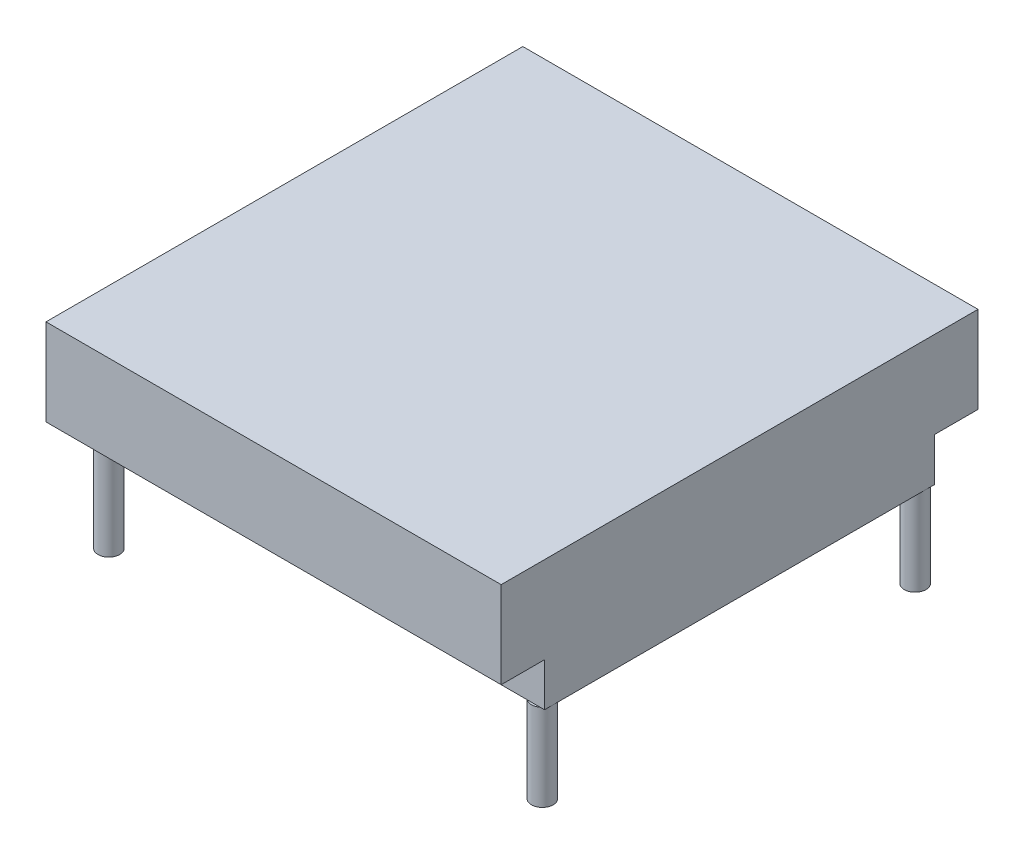
from build123d import *

# Parameters (mm, degrees)
SKETCH1_W           = 133.35
SKETCH1_H           = 139.7
BOSS_EXTRUDE1_DEPTH = 25.4
SKETCH2_W           = 50.8
SKETCH2_H           = 114.3
BOSS_EXTRUDE2_DEPTH = 12.7
SKETCH3_R           = 3.175
BOSS_EXTRUDE3_DEPTH = 38.1
SKETCH4_R           = 3.175
BOSS_EXTRUDE4_DEPTH = 38.1
SKETCH5_R           = 3.175
BOSS_EXTRUDE5_DEPTH = 25.4
SKETCH6_R           = 3.175
BOSS_EXTRUDE6_DEPTH = 25.4


with BuildPart() as part:
    # Sketch1 → Boss-Extrude1 (new body)
    with BuildSketch(Plane(origin=(0, 0, 0), x_dir=(1, 0, 0), z_dir=(0, 1, 0))):
        with Locations((66.675, 42.031328285)):
            Rectangle(SKETCH1_W, SKETCH1_H)
    extrude(amount=BOSS_EXTRUDE1_DEPTH)

    # Sketch2 → Boss-Extrude2 (add)
    with BuildSketch(Plane(origin=(0, 0, 0), x_dir=(-1, 0, 0), z_dir=(0, -1, 0))):
        with Locations((-107.95, 42.031328285)):
            Rectangle(SKETCH2_W, SKETCH2_H)
    extrude(amount=BOSS_EXTRUDE2_DEPTH)

    # Sketch3 → Boss-Extrude3 (add)
    with BuildSketch(Plane(origin=(0, 0, 0), x_dir=(-1, 0, 0), z_dir=(0, -1, 0))):
        with Locations((-3.175, 96.641328285)):
            Circle(SKETCH3_R)
    extrude(amount=BOSS_EXTRUDE3_DEPTH)

    # Sketch4 → Boss-Extrude4 (add)
    with BuildSketch(Plane(origin=(0, 0, 0), x_dir=(-1, 0, 0), z_dir=(0, -1, 0))):
        with Locations((-3.175, -12.578671715)):
            Circle(SKETCH4_R)
    extrude(amount=BOSS_EXTRUDE4_DEPTH)

    # Sketch5 → Boss-Extrude5 (add)
    with BuildSketch(Plane(origin=(0, -12.7, 0), x_dir=(-1, 0, 0), z_dir=(0, -1, 0))):
        with Locations((-130.175, 96.641328285)):
            Circle(SKETCH5_R)
    extrude(amount=BOSS_EXTRUDE5_DEPTH)

    # Sketch6 → Boss-Extrude6 (add)
    with BuildSketch(Plane(origin=(0, -12.7, 0), x_dir=(-1, 0, 0), z_dir=(0, -1, 0))):
        with Locations((-130.175, -12.578671715)):
            Circle(SKETCH6_R)
    extrude(amount=BOSS_EXTRUDE6_DEPTH)


solid = part.part
